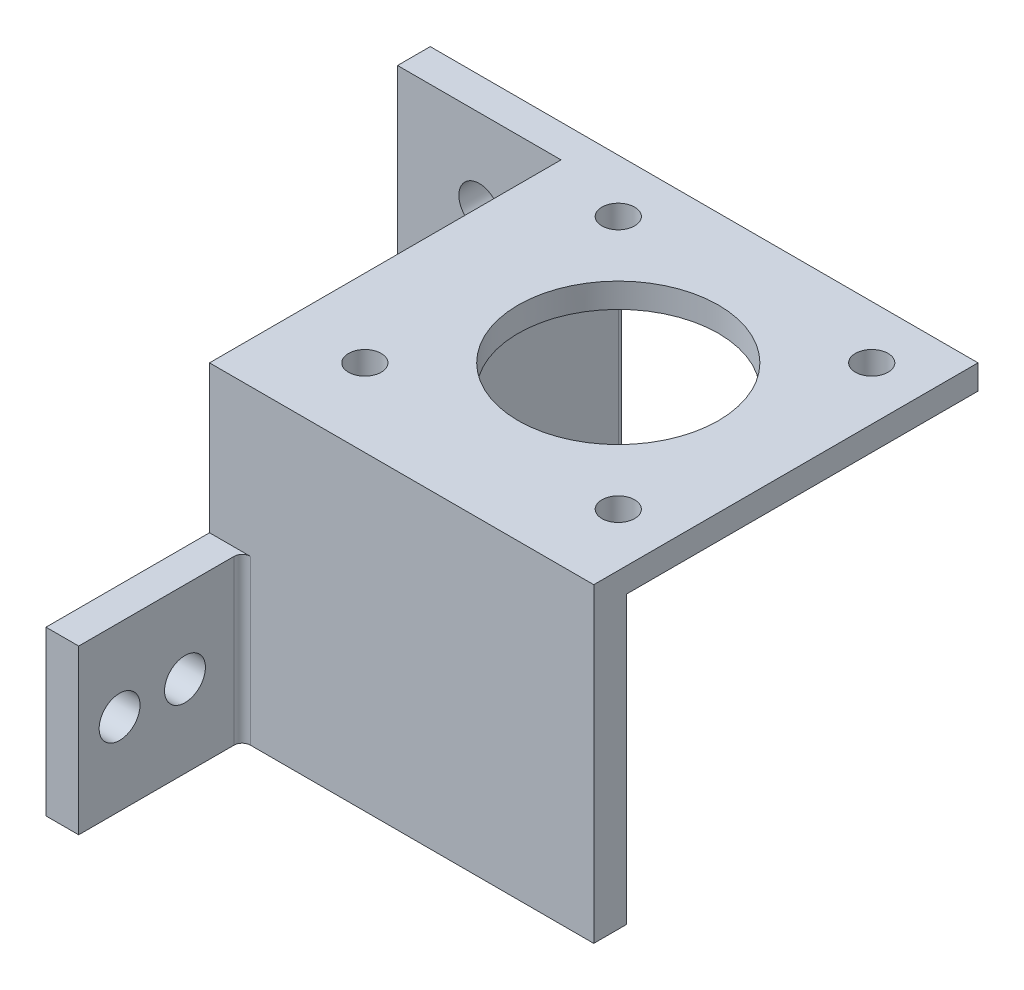
from build123d import *

# Parameters (mm, degrees)
BOSS_EXTRUDE1_DEPTH = 38
SKETCH2_W           = 43
SKETCH2_H           = 43
BOSS_EXTRUDE2_DEPTH = 3
SKETCH3_R           = 2
SKETCH3_R_2         = 12.25
CUT_EXTRUDE1_DEPTH  = 10
SKETCH4_R           = 2.5
CUT_EXTRUDE2_DEPTH  = 10
SKETCH5_W           = 20
SKETCH5_H           = 20
SKETCH5_R           = 2.5
BOSS_EXTRUDE3_DEPTH = 4
FILLET1_R           = 1


with BuildPart() as part:
    # Sketch1 → Boss-Extrude1 (new body)
    with BuildSketch(Plane(origin=(0, 0, 0), x_dir=(1, 0, 0), z_dir=(0, 1, 0))):
        Polygon((0, 0), (0, 34), (-20, 34), (-20, 38), (4, 38), (4, -5), (47, -5), (47, -9), (0, -9), align=None)
    extrude(amount=BOSS_EXTRUDE1_DEPTH)

    # Sketch2 → Boss-Extrude2 (add)
    with BuildSketch(Plane(origin=(0, 38, 0), x_dir=(1, 0, 0), z_dir=(0, 1, 0))):
        with Locations((25.5, 16.5)):
            Rectangle(SKETCH2_W, SKETCH2_H)
    extrude(amount=-BOSS_EXTRUDE2_DEPTH)

    # Sketch3 → Cut-Extrude1 (cut)
    with BuildSketch(Plane(origin=(0, 35, 0), x_dir=(-1, 0, 0), z_dir=(0, -1, 0))):
        with Locations((-40.5, 31.5)):
            Circle(SKETCH3_R)
        with Locations((-9.5, 31.5)):
            Circle(SKETCH3_R)
        with Locations((-9.5, 0.5)):
            Circle(SKETCH3_R)
        with Locations((-40.5, 0.5)):
            Circle(SKETCH3_R)
        with Locations((-25, 16)):
            Circle(SKETCH3_R_2)
    extrude(amount=-CUT_EXTRUDE1_DEPTH, mode=Mode.SUBTRACT)

    # Sketch4 → Cut-Extrude2 (cut)
    with BuildSketch(Plane.XY.offset(-34)):
        with Locations((-10, 10)):
            Circle(SKETCH4_R)
        with Locations((-10, 28)):
            Circle(SKETCH4_R)
    extrude(amount=-CUT_EXTRUDE2_DEPTH, mode=Mode.SUBTRACT)

    # Sketch5 → Boss-Extrude3 (add)
    with BuildSketch(Plane.ZY):
        with Locations((19, 10)):
            Rectangle(SKETCH5_W, SKETCH5_H)
        with Locations((16, 10)):
            Circle(SKETCH5_R, mode=Mode.SUBTRACT)
        with Locations((24, 10)):
            Circle(SKETCH5_R, mode=Mode.SUBTRACT)
    extrude(amount=-BOSS_EXTRUDE3_DEPTH)

    # Fillet1
    fillet1_edges = [part.edges().sort_by_distance(p)[0] for p in [
        (4, 17.5, -38),
        (4, 10, 9),
    ]]
    fillet(fillet1_edges, radius=FILLET1_R)


solid = part.part
